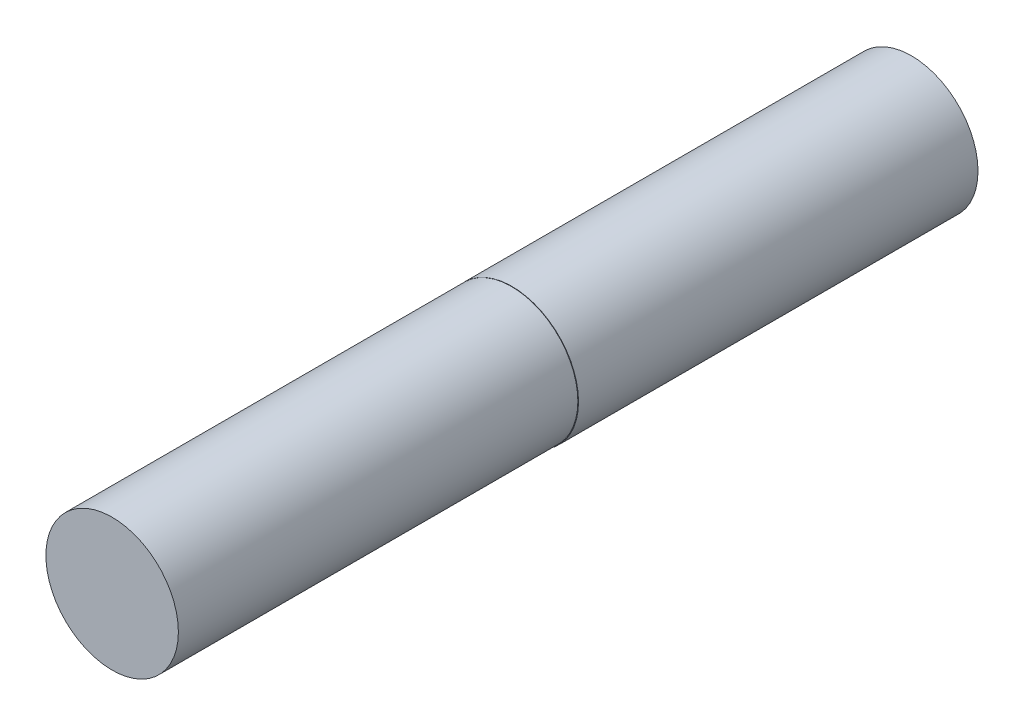
from build123d import *

# Parameters (mm, degrees)
BOSS_EXTRUDE1_DEPTH = 30
SKETCH2_R           = 4.97516062
BOSS_EXTRUDE2_DEPTH = 30


with BuildPart() as part:
    # Sketch1 → Boss-Extrude1 (new body)
    with BuildSketch(Plane.XY):
        with BuildLine():
            Line((-1.97516062, 1.5), (-1.97516062, 0))
            Line((-1.97516062, 0), (-1.97516062, -1.5))
            Line((-1.97516062, -1.5), (-4.744856627, -1.5))
            ThreePointArc((-4.744856627, -1.5), (0.783627877, -4.942088629), (5.02483938, 0))
            ThreePointArc((5.02483938, 0), (0.783627877, 4.942088629), (-4.744856627, 1.5))
            Line((-4.744856627, 1.5), (-1.97516062, 1.5))
        make_face()
    extrude(amount=BOSS_EXTRUDE1_DEPTH)

    # Sketch2 → Boss-Extrude2 (add)
    with BuildSketch(Plane.XY.offset(30)):
        Circle(SKETCH2_R)
    extrude(amount=BOSS_EXTRUDE2_DEPTH)


solid = part.part
